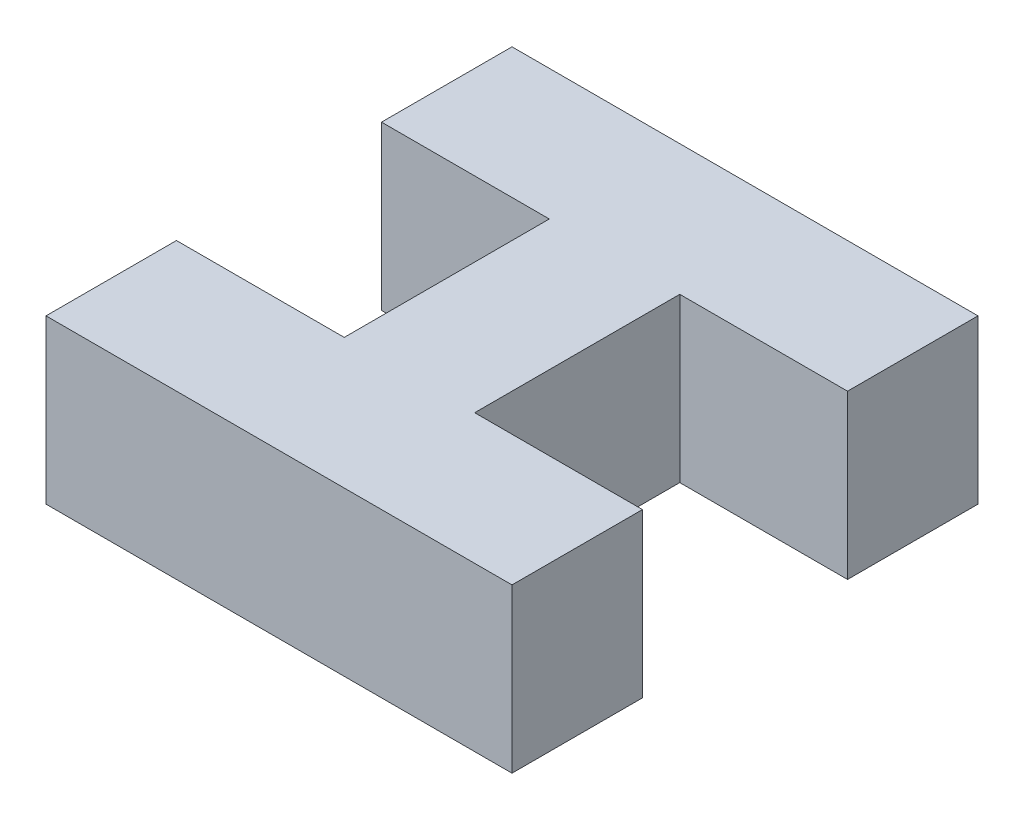
from build123d import *

# Parameters (mm, degrees)
BOSS_EXTRUDE1_DEPTH = 5


with BuildPart() as part:
    # Sketch2 → Boss-Extrude1 (new body)
    with BuildSketch(Plane(origin=(0, 0, 0), x_dir=(1, 0, 0), z_dir=(0, 1, 0))):
        Polygon((-3.14375, 3.14375), (-7.14375, 3.14375), (-7.14375, 7.14375), (7.14375, 7.14375), (7.14375, 3.14375), (3.14375, 3.14375), (2, 3.14375), (2, 2), (2, -2), (2, -3.14375), (3.14375, -3.14375), (7.14375, -3.14375), (7.14375, -7.14375), (-7.14375, -7.14375), (-7.14375, -3.14375), (-3.14375, -3.14375), (-2, -3.14375), (-2, -2), (-2, 2), (-2, 3.14375), align=None)
    extrude(amount=BOSS_EXTRUDE1_DEPTH)


solid = part.part
